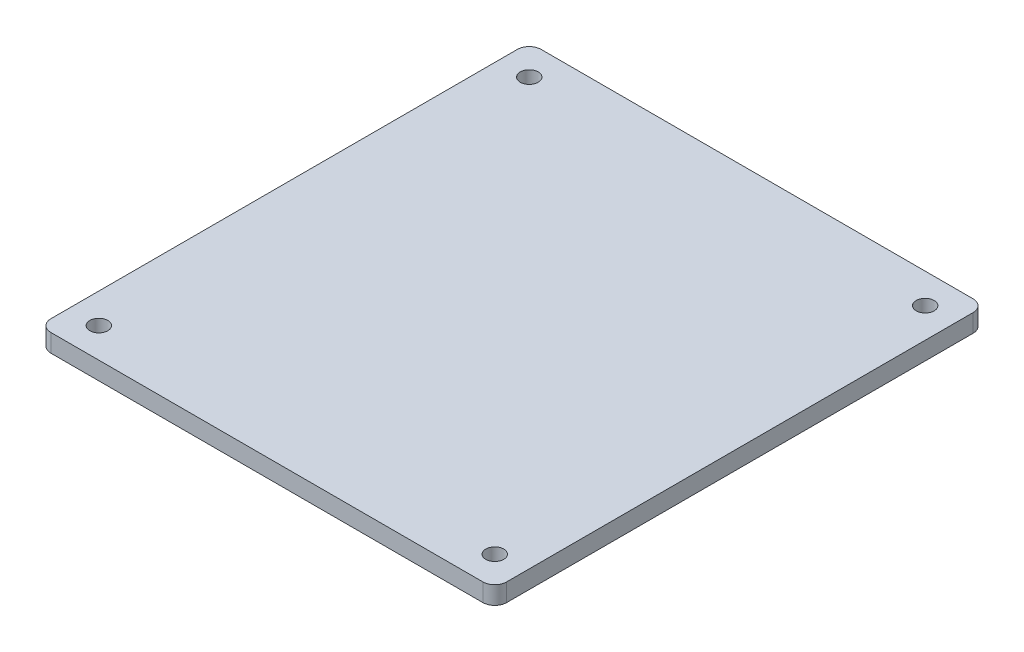
from build123d import *

# Parameters (mm, degrees)
SKETCH1_R           = 1.190625
BOSS_EXTRUDE1_DEPTH = 2.38125


with BuildPart() as part:
    # Sketch1 → Boss-Extrude1 (new body)
    with BuildSketch(Plane(origin=(0, 0, 0), x_dir=(1, 0, 0), z_dir=(0, 1, 0))):
        with BuildLine():
            Line((1.5875, 0), (58.8645, 0))
            ThreePointArc((58.8645, 0), (59.987032015, 0.464967985), (60.452, 1.5875))
            Line((60.452, 1.5875), (60.452, 63.4365))
            ThreePointArc((60.452, 63.4365), (59.987032015, 64.559032015), (58.8645, 65.024))
            Line((58.8645, 65.024), (1.5875, 65.024))
            ThreePointArc((1.5875, 65.024), (0.464967985, 64.559032015), (0, 63.4365))
            Line((0, 63.4365), (0, 1.5875))
            ThreePointArc((0, 1.5875), (0.464967985, 0.464967985), (1.5875, 0))
        make_face()
        with Locations((3.96875, 3.96875)):
            Circle(SKETCH1_R, mode=Mode.SUBTRACT)
        with Locations((3.96875, 61.05525)):
            Circle(SKETCH1_R, mode=Mode.SUBTRACT)
        with Locations((56.48325, 61.05525)):
            Circle(SKETCH1_R, mode=Mode.SUBTRACT)
        with Locations((56.48325, 3.96875)):
            Circle(SKETCH1_R, mode=Mode.SUBTRACT)
    extrude(amount=BOSS_EXTRUDE1_DEPTH)


solid = part.part
